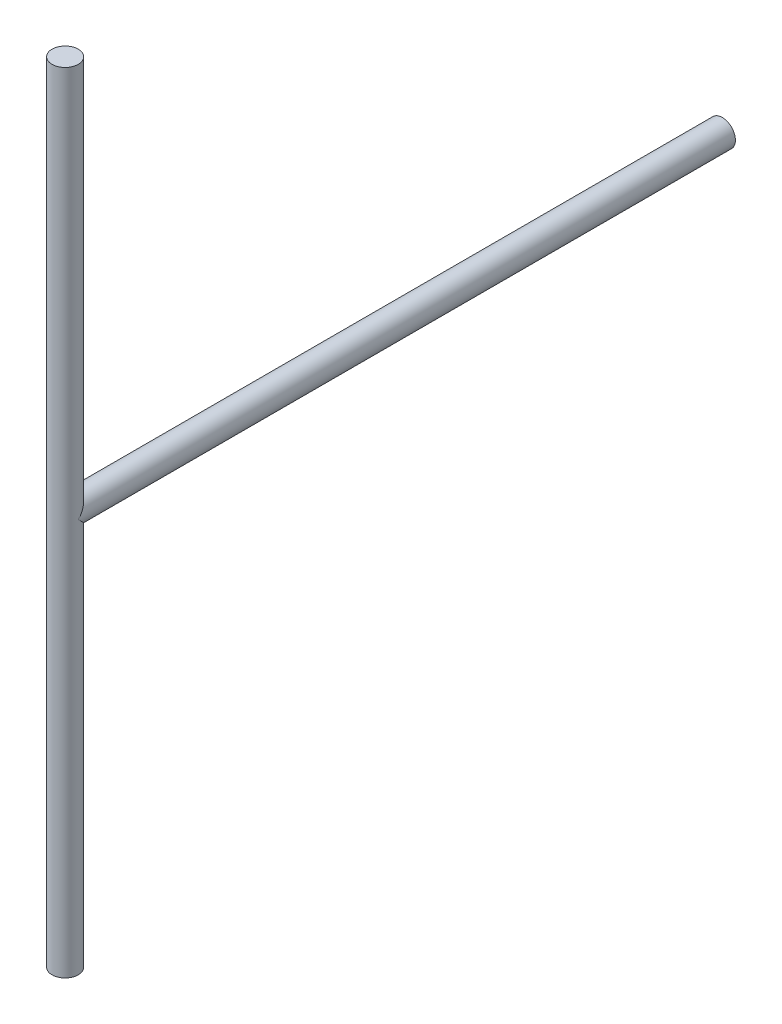
from build123d import *

# Parameters (mm, degrees)
ESQUISSE1_R             = 1
BOSS_EXTRU_1_DEPTH      = 50
ESQUISSE2_R             = 1
BOSS_EXTRU_2_DEPTH      = 30
BOSS_EXTRU_2_DEPTH_BACK = 30


with BuildPart() as part:
    # Esquisse1 → Boss.-Extru.1 (new body)
    with BuildSketch(Plane.XY):
        Circle(ESQUISSE1_R)
    extrude(amount=-BOSS_EXTRU_1_DEPTH)

    # Esquisse2 → Boss.-Extru.2 (add, two sides)
    with BuildSketch(Plane(origin=(0, 0, 0), x_dir=(1, 0, 0), z_dir=(0, 1, 0))) as boss_extru_2_sk:
        with Locations(Location((0, 0, 0), (0, 0, 270))):  # turned: the seam where the file's is
            Circle(ESQUISSE2_R)
    extrude(amount=BOSS_EXTRU_2_DEPTH)
    extrude(boss_extru_2_sk.sketch, amount=-BOSS_EXTRU_2_DEPTH_BACK)


solid = part.part
